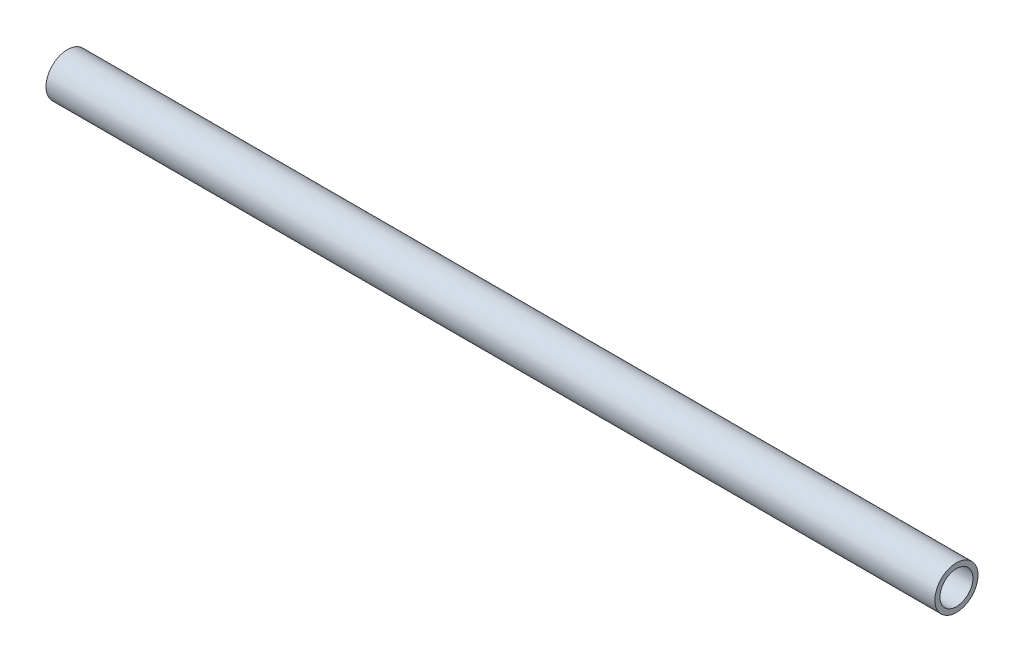
from build123d import *

# Parameters (mm, degrees)
SKETCH1_R           = 8
SKETCH1_R_2         = 6.11476785
BOSS_EXTRUDE1_DEPTH = 330


with BuildPart() as part:
    # Sketch1 → Boss-Extrude1 (new body)
    with BuildSketch(Plane(origin=(0, 0, 0), x_dir=(0, 0, -1), z_dir=(1, 0, 0))):
        Circle(SKETCH1_R)
        Circle(SKETCH1_R_2, mode=Mode.SUBTRACT)
    extrude(amount=BOSS_EXTRUDE1_DEPTH)


solid = part.part
